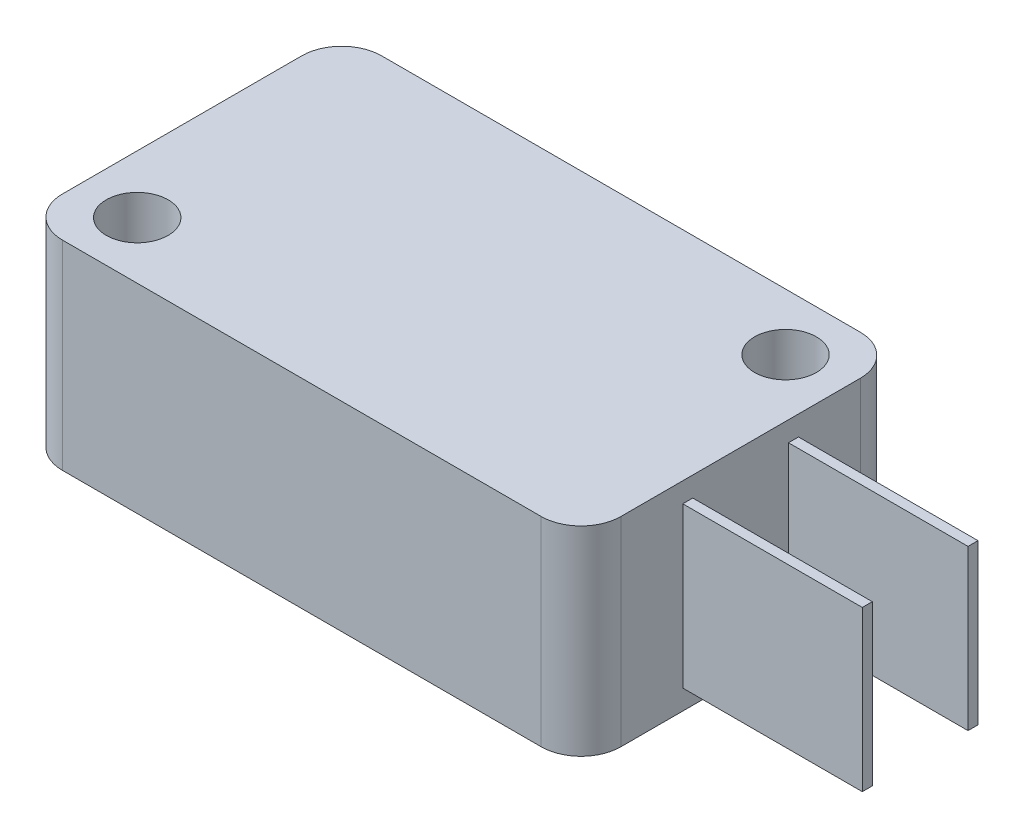
from build123d import *

# Parameters (mm, degrees)
SKETCH_1_W          = 28
SKETCH_1_H          = 16
EXTRUDE_1_DEPTH     = 10
FILLET_1_R          = 2
SKETCH_2_R          = 1.55
CUT_EXTRUDE_1_DEPTH = 10
SKETCH_3_W          = 0.5
SKETCH_3_H          = 8
EXTRUDE_2_DEPTH     = 9
SKETCH_4_W          = 3
SKETCH_4_H          = 3
EXTRUDE_3_DEPTH     = 2.5
FILLET_2_R          = 1


with BuildPart() as part:
    # 스케치1 → 보스-돌출1 (new body)
    with BuildSketch(Plane(origin=(0, 0, 0), x_dir=(1, 0, 0), z_dir=(0, 1, 0))):
        Rectangle(SKETCH_1_W, SKETCH_1_H)
    extrude(amount=EXTRUDE_1_DEPTH)

    # 필렛1
    fillet_1_edges = [part.edges().sort_by_distance(p)[0] for p in [
        (-14, 5, -8),
        (14, 5, -8),
        (14, 5, 8),
        (-14, 5, 8),
    ]]
    fillet(fillet_1_edges, radius=FILLET_1_R)

    # 스케치2 → 컷-돌출1 (cut)
    with BuildSketch(Plane(origin=(0, 10, 0), x_dir=(1, 0, 0), z_dir=(0, 1, 0))):
        with Locations((11.1, 5.15)):
            Circle(SKETCH_2_R)
        with Locations((-11.1, -5.15)):
            Circle(SKETCH_2_R)
    extrude(amount=-CUT_EXTRUDE_1_DEPTH, mode=Mode.SUBTRACT)

    # 스케치3 → 보스-돌출2 (add)
    with BuildSketch(Plane(origin=(14, 0, 0), x_dir=(0, 0, -1), z_dir=(1, 0, 0))):
        with Locations((-2.65, 5)):
            Rectangle(SKETCH_3_W, SKETCH_3_H)
        with Locations((2.65, 5)):
            Rectangle(SKETCH_3_W, SKETCH_3_H)
    extrude(amount=EXTRUDE_2_DEPTH)

    # 스케치4 → 보스-돌출3 (add)
    with BuildSketch(Plane(origin=(0, 0, -8), x_dir=(-1, 0, 0), z_dir=(0, 0, -1))):
        with Locations((6.465564218, 5)):
            Rectangle(SKETCH_4_W, SKETCH_4_H)
    extrude(amount=EXTRUDE_3_DEPTH)

    # 필렛2
    fillet_2_edges = [part.edges().sort_by_distance(p)[0] for p in [
        (-4.965564218, 5, -10.5),
        (-7.965564218, 5, -10.5),
    ]]
    fillet(fillet_2_edges, radius=FILLET_2_R)


solid = part.part
